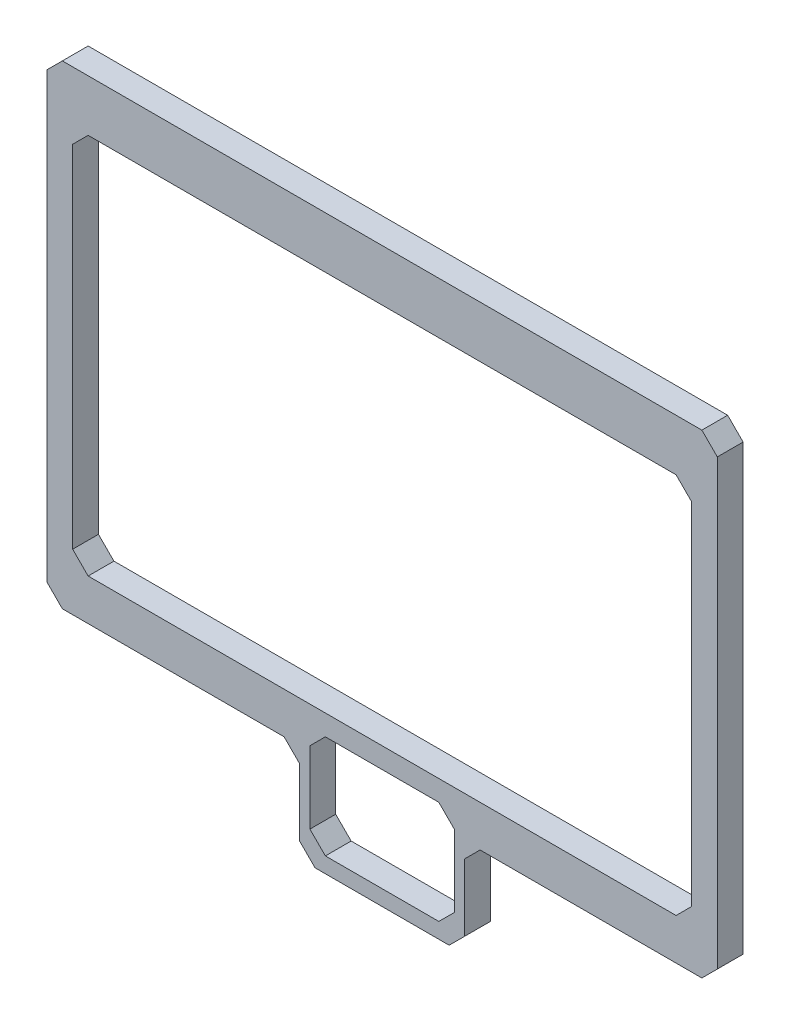
from build123d import *

# Parameters (mm, degrees)
BOSS_EXTRUDE1_DEPTH = 5


with BuildPart() as part:
    # Sketch1 → Boss-Extrude1 (new body)
    with BuildSketch(Plane.XY):
        Polygon((3, 10), (127, 10), (130, 7), (130, -79), (127, -82), (84, -82), (81, -85), (81, -98), (78, -101), (52, -101), (49, -98), (49, -85), (46, -82), (3, -82), (0, -79), (0, 7), align=None)
        Polygon((125, -71), (125, -3), (122, 0), (8, 0), (5, -3), (5, -71), (8, -74), (122, -74), align=None, mode=Mode.SUBTRACT)
        Polygon((54, -78), (76, -78), (79, -81), (79, -95), (76, -98), (54, -98), (51, -95), (51, -81), align=None, mode=Mode.SUBTRACT)
    extrude(amount=BOSS_EXTRUDE1_DEPTH)


solid = part.part
